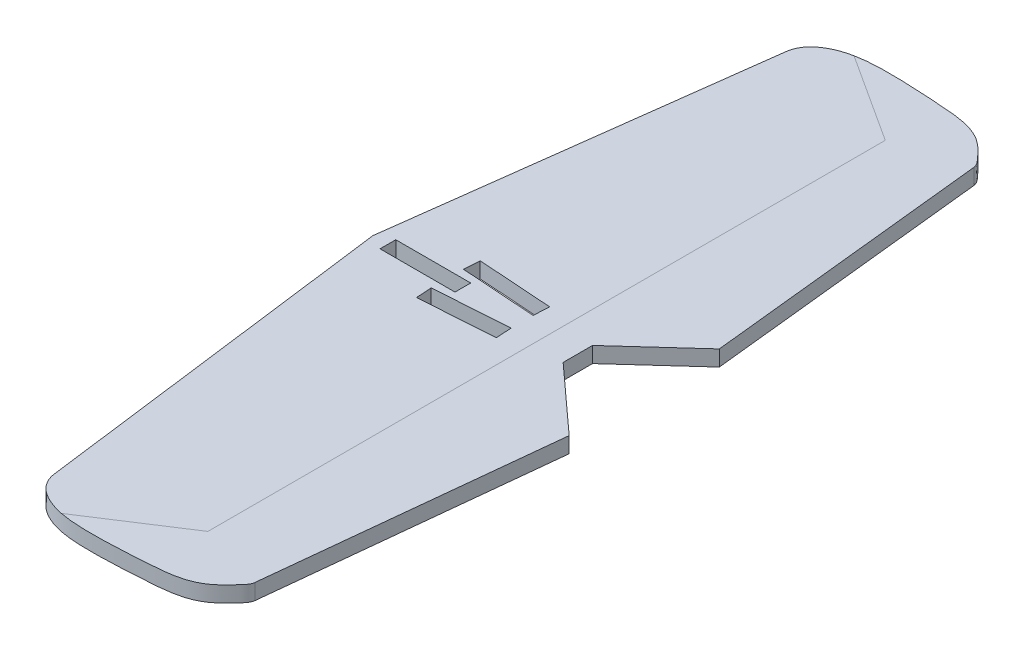
from build123d import *

# Parameters (mm, degrees)
BOSS_EXTRUDE1_DEPTH  = 5.334
FUSELAGE_SLOTS_REACH = 165.568
RUDDER_SLOT_REACH    = 165.568
SKETCH4_W            = 25.4
SKETCH4_H            = 5.334


with BuildPart() as part:
    # Sketch1 → Boss-Extrude1 (new body)
    with BuildSketch(Plane(origin=(0, 0, 0), x_dir=(1, 0, 0), z_dir=(0, 1, 0))):
        with BuildLine():
            Line((15.970216498, 123.888067637), (0, 0))
            Line((0, 0), (15.970216498, -123.888067637))
            add(Edge.make_bspline(
                [(15.970216498, -123.888067637), (16.496348793, -127.969509697), (23.126657383, -134.082989784), (33.998204042, -135.21680351), (46.054708275, -135.145094132), (57.878857589, -134.457454778), (71.986589127, -133.257487146), (78.619292876, -126.55856753), (81.681846945, -123.009151118), (81.805097467, -121.83833135)],
                knots=[0, 0, 0, 0, 0.137873605, 0.340707261, 0.419473129, 0.623495844, 0.825009795, 0.952423895, 1, 1, 1, 1], degree=3))
            Line((81.805097467, -121.83833135), (91.952571506, -25.442283053))
            Line((91.952571506, -25.442283053), (69.447862014, -4.983456242))
            Line((69.447862014, -4.983456242), (69.447862014, 4.983456242))
            Line((69.447862014, 4.983456242), (91.952571506, 25.442283053))
            Line((91.952571506, 25.442283053), (81.805097467, 121.83833135))
            add(Edge.make_bspline(
                [(81.805097467, 121.83833135), (81.681846945, 123.009151118), (78.619292876, 126.55856753), (71.986589127, 133.257487146), (57.878857589, 134.457454778), (46.054708275, 135.145094132), (33.998204042, 135.21680351), (23.126657383, 134.082989784), (16.496348793, 127.969509697), (15.970216498, 123.888067637)],
                knots=[0.230135461, 0.230135461, 0.230135461, 0.230135461, 0.277711566, 0.405125666, 0.606639617, 0.810662332, 0.8894282, 1.092261856, 1.230135461, 1.230135461, 1.230135461, 1.230135461], degree=3))
        make_face()
    extrude(amount=BOSS_EXTRUDE1_DEPTH)

    # Sketch3 → Fuselage Slots (cut, up to next)
    with BuildSketch(Plane(origin=(0, 5.334, 0), x_dir=(1, 0, 0), z_dir=(0, 1, 0)), mode=Mode.PRIVATE) as fuselage_slots_sk1:
        Polygon((50.911526431, 9.044666188), (25.571689625, 10.791855537), (25.204779861, 5.470489808), (50.544616668, 3.723300459), align=None)
    fuselage_slots_tool1 = extrude(fuselage_slots_sk1.sketch, amount=-FUSELAGE_SLOTS_REACH, mode=Mode.PRIVATE) & part.part
    # Sketch3 → Fuselage Slots (cut, up to next)
    with BuildSketch(Plane(origin=(0, 5.334, 0), x_dir=(1, 0, 0), z_dir=(0, 1, 0)), mode=Mode.PRIVATE) as fuselage_slots_sk2:
        Polygon((25.571689625, -10.791855537), (50.911526431, -9.044666188), (50.544616668, -3.723300459), (25.204779861, -5.470489808), align=None)
    fuselage_slots_tool2 = extrude(fuselage_slots_sk2.sketch, amount=-FUSELAGE_SLOTS_REACH, mode=Mode.PRIVATE) & part.part
    add(fuselage_slots_tool1.solids().sort_by_distance((38.058153, 5.334, -7.257578))[0], mode=Mode.SUBTRACT)
    add(fuselage_slots_tool2.solids().sort_by_distance((38.058153, 5.334, 7.257578))[0], mode=Mode.SUBTRACT)

    # Sketch4 → Rudder Slot (cut, up to next)
    with BuildSketch(Plane(origin=(0, 5.334, 0), x_dir=(1, 0, 0), z_dir=(0, 1, 0)), mode=Mode.PRIVATE) as rudder_slot_sk1:
        with Locations((17.78, 0)):
            Rectangle(SKETCH4_W, SKETCH4_H)
    rudder_slot_tool1 = extrude(rudder_slot_sk1.sketch, amount=-RUDDER_SLOT_REACH, mode=Mode.PRIVATE) & part.part
    add(rudder_slot_tool1.solids().sort_by_distance((17.78, 5.334, 0))[0], mode=Mode.SUBTRACT)


solid = part.part
